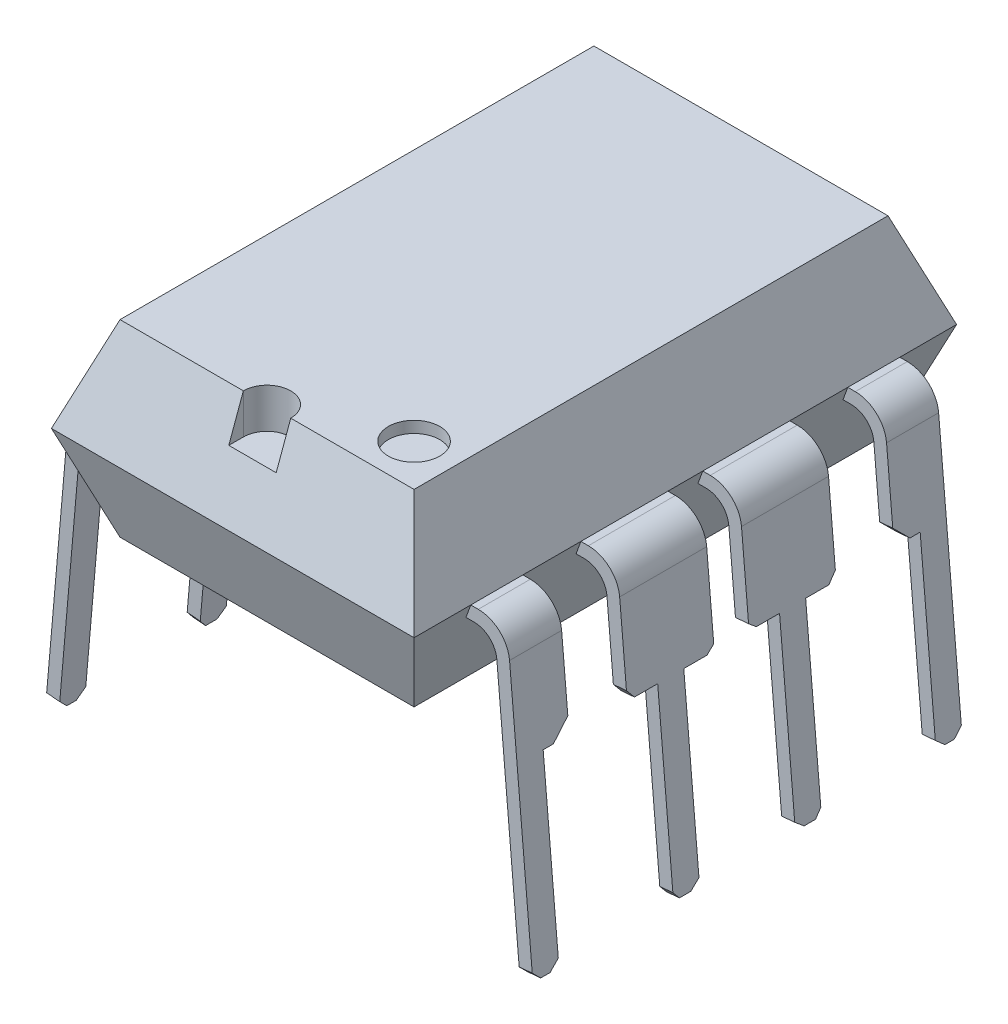
from build123d import *

# Parameters (mm, degrees)
BOSS_EXTRUDE1_DEPTH     = 9.5
CUT_EXTRUDE2_DEPTH      = 9.5
CUT_EXTRUDE2_DEPTH_BACK = 9.5
CUT_EXTRUDE3_DEPTH      = 0.7
SKETCH4_W               = 0.83
SKETCH4_H               = 0.7
CUT_EXTRUDE4_DEPTH      = 0.7
BOSS_EXTRUDE2_START     = -0.762
BOSS_EXTRUDE2_DEPTH     = 0.912
CUT_EXTRUDE5_DEPTH      = 10.15
SKETCH9_R               = 0.45
CUT_EXTRUDE7_DEPTH      = 0.2
BOSS_EXTRUDE3_DEPTH     = 0.762
CUT_EXTRUDE6_DEPTH      = 0.762
MIRROR2_START           = -0.762
MIRROR2_COPY_1_DEPTH    = 0.912
MIRROR2_COPY_2_DEPTH    = 10.15
MIRROR2_COPY_3_DEPTH    = 0.762
MIRROR2_COPY_4_DEPTH    = 0.762


with BuildPart() as part:
    # Sketch1 → Boss-Extrude1 (new body)
    with BuildSketch(Plane.XY):
        Polygon((-24.934327538, -0.557710036), (-25.534514454, 1.091289964), (-30.684140621, 1.091289964), (-31.284327538, -0.557710036), (-30.683412681, -2.208710036), (-25.535242395, -2.208710036), align=None)
    extrude(amount=-BOSS_EXTRUDE1_DEPTH)

    # Sketch2 → Cut-Extrude2 (cut, two sides)
    with BuildSketch(Plane(origin=(-30.683898403, -0.0067685, 0), x_dir=(0, 0, 1), z_dir=(-0.9999999756704636, -0.00022058801540043594, 0))) as cut_extrude2_sk:
        Polygon((-0.616330332, -2.245563479), (0, -0.552209808), (0, -2.212209808), align=None)
        Polygon((-0.60064854, 1.098058491), (0, -0.552209808), (0, 1.098058491), align=None)
        Polygon((-9.5, -2.212209808), (-8.892247033, -2.221997362), (-9.5, -0.552209808), align=None)
        Polygon((-9.5, -0.552209808), (-9.5, 1.098058491), (-8.89935146, 1.098058491), align=None)
    extrude(amount=CUT_EXTRUDE2_DEPTH, mode=Mode.SUBTRACT)
    extrude(cut_extrude2_sk.sketch, amount=-CUT_EXTRUDE2_DEPTH_BACK, mode=Mode.SUBTRACT)

    # Sketch3 → Cut-Extrude3 (cut)
    with BuildSketch(Plane(origin=(0, 1.091289964, 0), x_dir=(1, 0, 0), z_dir=(0, 1, 0))):
        with BuildLine():
            Line((-28.524327536, 0.600475134), (-27.694327539, 0.600408495))
            ThreePointArc((-27.694327539, 0.600408495), (-28.109294218, 1.015441813), (-28.524327536, 0.600475134))
        make_face()
    extrude(amount=-CUT_EXTRUDE3_DEPTH, mode=Mode.SUBTRACT)

    # Sketch4 → Cut-Extrude4 (cut)
    with BuildSketch(Plane(origin=(4.8027e-05, 0, -0.598184984), x_dir=(-0.9999999967769609, 0, -8.028747138262029e-05), z_dir=(8.028747138262029e-05, 0, -0.9999999967769609))):
        with Locations((28.109375655, 0.741289964)):
            Rectangle(SKETCH4_W, SKETCH4_H)
    extrude(amount=-CUT_EXTRUDE4_DEPTH, mode=Mode.SUBTRACT)


with BuildPart() as boss_extrude2_tool:
    # Sketch5 → Boss-Extrude2 (new body)
    with BuildSketch(Plane.XY.offset(-1.143).offset(BOSS_EXTRUDE2_START)):
        with BuildLine():
            Line((-24.934327536, -0.557713614), (-24.80305479, -0.557713614))
            ThreePointArc((-24.80305479, -0.557713614), (-24.431480176, -0.702211079), (-24.255147706, -1.059777956))
            Line((-24.255147706, -1.059777956), (-23.8457982, -5.738664215))
            Line((-23.8457982, -5.738664215), (-24.074922981, -5.758710036))
            Line((-24.074922981, -5.758710036), (-24.477883405, -1.152851317))
            ThreePointArc((-24.477883405, -1.152851317), (-24.606125201, -0.892802679), (-24.876361284, -0.787713614))
            Line((-24.876361284, -0.787713614), (-25.018040872, -0.787713614))
            Line((-25.018040872, -0.787713614), (-24.934327536, -0.557713614))
        make_face()
    boss_extrude2 = extrude(amount=BOSS_EXTRUDE2_DEPTH)


with BuildPart() as part_1:
    add(part.part)


with BuildPart() as part_2:
    # Boss-Extrude2: joined with boss_extrude2_tool
    add(part_1.part.fuse(boss_extrude2_tool.part, tol=0.00001))

    # Sketch6 → Cut-Extrude5 (cut)
    with BuildSketch(Plane(origin=(-24.162916864, -2.113981303, 0), x_dir=(0, 0, -1), z_dir=(0.9961946980917458, 0.08715574274765556, 0))):
        Polygon((0.993, -3.502234692), (0.993, -3.638528611), (1.129293919, -3.638528611), align=None)
        Polygon((1.449, -3.502234692), (1.292810168, -3.638528611), (1.449, -3.638528611), align=None)
        Polygon((1.449, -3.502234692), (1.449, -3.638528611), (1.905, -3.638528611), (1.905, -0.186528611), (1.628, -0.463528611), (1.449, -0.463528611), align=None)
    cut_extrude5 = extrude(amount=-CUT_EXTRUDE5_DEPTH, mode=Mode.SUBTRACT)

    # Sketch9 → Cut-Extrude7 (cut)
    with BuildSketch(Plane(origin=(0, 1.091289964, 0), x_dir=(1, 0, 0), z_dir=(0, 1, 0))):
        with Locations(Location((-26.264514454, 1.330293701, 0), (0, 0, 180))):
            Circle(SKETCH9_R)
    extrude(amount=-CUT_EXTRUDE7_DEPTH, mode=Mode.SUBTRACT)

    # Sketch7 → Boss-Extrude3 (add, symmetric)
    with BuildSketch(Plane.XY.offset(-3.683)):
        with BuildLine():
            Line((-24.934327538, -0.557710036), (-24.803054792, -0.557710036))
            ThreePointArc((-24.803054792, -0.557710036), (-24.431480177, -0.7022075), (-24.255147708, -1.059774377))
            Line((-24.255147708, -1.059774377), (-23.845798202, -5.738660636))
            Line((-23.845798202, -5.738660636), (-24.074922983, -5.758706457))
            Line((-24.074922983, -5.758706457), (-24.477883406, -1.152847739))
            ThreePointArc((-24.477883406, -1.152847739), (-24.606125202, -0.892799101), (-24.876361286, -0.787710036))
            Line((-24.876361286, -0.787710036), (-25.018040873, -0.787710036))
            Line((-25.018040873, -0.787710036), (-24.934327538, -0.557710036))
        make_face()
    boss_extrude3 = extrude(amount=BOSS_EXTRUDE3_DEPTH, both=True)

    # Sketch8 → Cut-Extrude6 (cut)
    with BuildSketch(Plane(origin=(-24.162916555, -2.113981276, 0), x_dir=(0, 0, -1), z_dir=(0.9961946980917459, 0.08715574274765502, 0))):
        Polygon((2.921, -3.638525046), (3.4545, -3.638525046), (3.4545, -3.512139824), (3.4545, -0.463528611), (3.048, -0.463528611), (2.921, -0.309075706), align=None)
        Polygon((3.9115, -0.463528611), (3.9115, -3.512139824), (3.9115, -3.638525046), (4.445, -3.638525046), (4.445, -0.359101958), (4.318, -0.463528611), align=None)
        Polygon((3.4545, -3.512139824), (3.4545, -3.638525046), (3.558421148, -3.638525046), align=None)
        Polygon((3.9115, -3.512139824), (3.757794765, -3.638525046), (3.9115, -3.638525046), align=None)
    cut_extrude6 = extrude(amount=-CUT_EXTRUDE6_DEPTH, mode=Mode.SUBTRACT)

    # Mirror1: Boss-Extrude2, Cut-Extrude5, Boss-Extrude3, Cut-Extrude6 across plane
    add(boss_extrude2.mirror(Plane.XY.offset(-4.75)))
    add(cut_extrude5.mirror(Plane.XY.offset(-4.75)), mode=Mode.SUBTRACT)
    add(boss_extrude3.mirror(Plane.XY.offset(-4.75)))
    add(cut_extrude6.mirror(Plane.XY.offset(-4.75)), mode=Mode.SUBTRACT)

    # Mirror2: Boss-Extrude2, Cut-Extrude5, Boss-Extrude3, Cut-Extrude6 across plane
    add(boss_extrude2.mirror(Plane(origin=(-28.109327538, 0, 0), x_dir=(0, 0, 1), z_dir=(1, 0, 0))))
    add(cut_extrude5.mirror(Plane(origin=(-28.109327538, 0, 0), x_dir=(0, 0, 1), z_dir=(1, 0, 0))), mode=Mode.SUBTRACT)
    add(boss_extrude3.mirror(Plane(origin=(-28.109327538, 0, 0), x_dir=(0, 0, 1), z_dir=(1, 0, 0))))
    add(cut_extrude6.mirror(Plane(origin=(-28.109327538, 0, 0), x_dir=(0, 0, 1), z_dir=(1, 0, 0))), mode=Mode.SUBTRACT)


with BuildPart() as mirror2_copy_1_tool:
    # Mirror2 copy 1 sketch → Mirror2 copy 1 (new body)
    with BuildSketch(Plane(origin=(-56.218655076, 0, -8.357), x_dir=(-1, 0, 0), z_dir=(0, 0, -1)).offset(MIRROR2_START)):
        with BuildLine():
            Line((-24.934327536, -0.557713614), (-24.80305479, -0.557713614))
            ThreePointArc((-24.80305479, -0.557713614), (-24.431480176, -0.702211079), (-24.255147706, -1.059777956))
            Line((-24.255147706, -1.059777956), (-23.8457982, -5.738664215))
            Line((-23.8457982, -5.738664215), (-24.074922981, -5.758710036))
            Line((-24.074922981, -5.758710036), (-24.477883405, -1.152851317))
            ThreePointArc((-24.477883405, -1.152851317), (-24.606125201, -0.892802679), (-24.876361284, -0.787713614))
            Line((-24.876361284, -0.787713614), (-25.018040872, -0.787713614))
            Line((-25.018040872, -0.787713614), (-24.934327536, -0.557713614))
        make_face()
    extrude(amount=MIRROR2_COPY_1_DEPTH)


with BuildPart() as part_3:
    add(part_2.part)


with BuildPart() as part_4:
    # Mirror2 copy 1: joined with mirror2_copy_1_tool
    add(part_3.part.fuse(mirror2_copy_1_tool.part, tol=0.00001))

    # Mirror2 copy 2 sketch → Mirror2 copy 2 (cut)
    with BuildSketch(Plane(origin=(-32.055738211, -2.113981303, -9.5), x_dir=(0, 0, 1), z_dir=(-0.9961946980917458, 0.08715574274765556, 0))):
        Polygon((0.993, -3.502234692), (0.993, -3.638528611), (1.129293919, -3.638528611), align=None)
        Polygon((1.449, -3.502234692), (1.292810168, -3.638528611), (1.449, -3.638528611), align=None)
        Polygon((1.449, -3.502234692), (1.449, -3.638528611), (1.905, -3.638528611), (1.905, -0.186528611), (1.628, -0.463528611), (1.449, -0.463528611), align=None)
    extrude(amount=-MIRROR2_COPY_2_DEPTH, mode=Mode.SUBTRACT)

    # Mirror2 copy 3 sketch → Mirror2 copy 3 (add, symmetric)
    with BuildSketch(Plane(origin=(-56.218655076, 0, -5.817), x_dir=(-1, 0, 0), z_dir=(0, 0, -1))):
        with BuildLine():
            Line((-24.934327538, -0.557710036), (-24.803054792, -0.557710036))
            ThreePointArc((-24.803054792, -0.557710036), (-24.431480177, -0.7022075), (-24.255147708, -1.059774377))
            Line((-24.255147708, -1.059774377), (-23.845798202, -5.738660636))
            Line((-23.845798202, -5.738660636), (-24.074922983, -5.758706457))
            Line((-24.074922983, -5.758706457), (-24.477883406, -1.152847739))
            ThreePointArc((-24.477883406, -1.152847739), (-24.606125202, -0.892799101), (-24.876361286, -0.787710036))
            Line((-24.876361286, -0.787710036), (-25.018040873, -0.787710036))
            Line((-25.018040873, -0.787710036), (-24.934327538, -0.557710036))
        make_face()
    extrude(amount=MIRROR2_COPY_3_DEPTH, both=True)

    # Mirror2 copy 4 sketch → Mirror2 copy 4 (cut)
    with BuildSketch(Plane(origin=(-32.055738521, -2.113981276, -9.5), x_dir=(0, 0, 1), z_dir=(-0.9961946980917459, 0.08715574274765502, 0))):
        Polygon((2.921, -3.638525046), (3.4545, -3.638525046), (3.4545, -3.512139824), (3.4545, -0.463528611), (3.048, -0.463528611), (2.921, -0.309075706), align=None)
        Polygon((3.9115, -0.463528611), (3.9115, -3.512139824), (3.9115, -3.638525046), (4.445, -3.638525046), (4.445, -0.359101958), (4.318, -0.463528611), align=None)
        Polygon((3.4545, -3.512139824), (3.4545, -3.638525046), (3.558421148, -3.638525046), align=None)
        Polygon((3.9115, -3.512139824), (3.757794765, -3.638525046), (3.9115, -3.638525046), align=None)
    extrude(amount=-MIRROR2_COPY_4_DEPTH, mode=Mode.SUBTRACT)


solid = part_4.part
